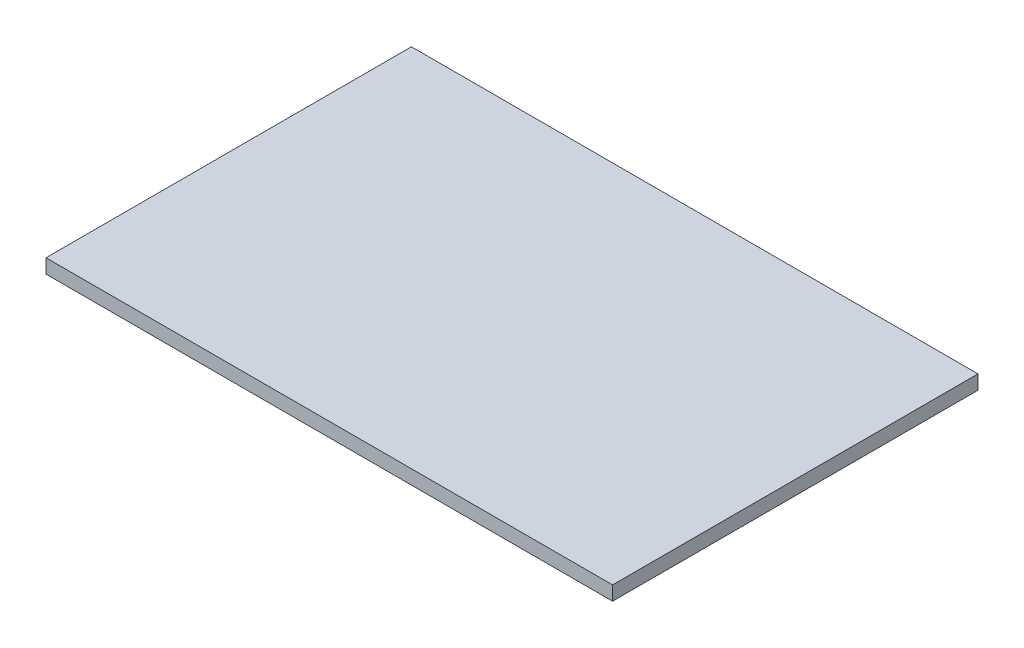
from build123d import *

# Parameters (mm, degrees)
ESQUISSE1_W      = 400
ESQUISSE1_H      = 258
EXTRUSION1_DEPTH = 10


with BuildPart() as part:
    # Esquisse1 → Extrusion1 (new body)
    with BuildSketch(Plane(origin=(0, 0, 0), x_dir=(1, 0, 0), z_dir=(0, 1, 0))):
        with Locations((200, 129)):
            Rectangle(ESQUISSE1_W, ESQUISSE1_H)
    extrude(amount=EXTRUSION1_DEPTH)


solid = part.part
